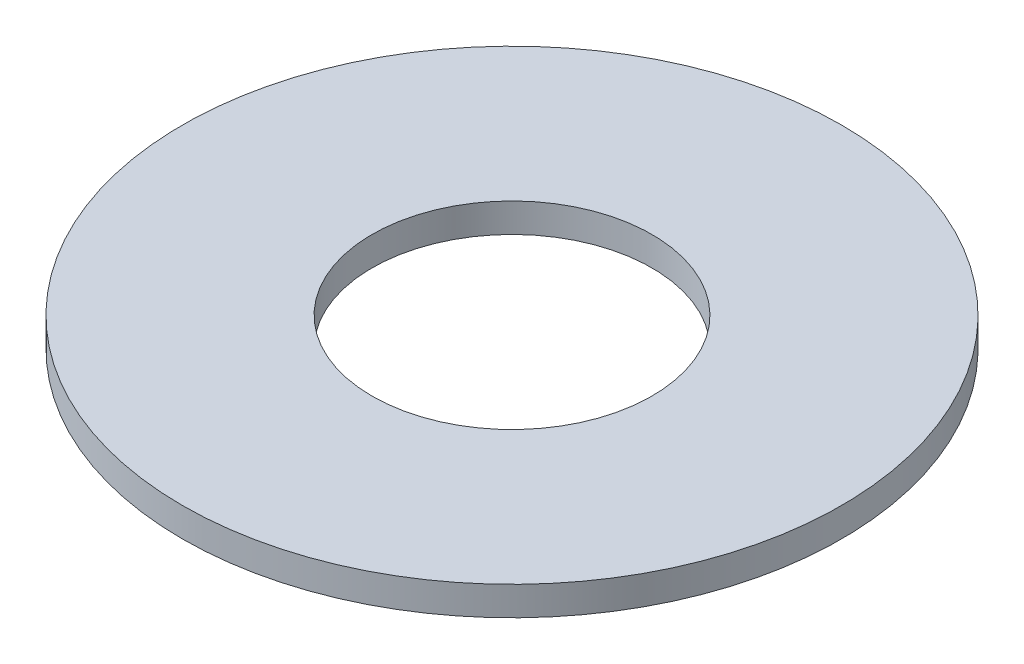
from build123d import *

# Parameters (mm, degrees)
SKETCH1_R           = 15.875
BOSS_EXTRUDE1_DEPTH = 1.397
SKETCH5_R           = 6.7437
CUT_EXTRUDE1_DEPTH  = 2.397


with BuildPart() as part:
    # Sketch1 → Boss-Extrude1 (new body)
    with BuildSketch(Plane(origin=(0, 0, 0), x_dir=(1, 0, 0), z_dir=(0, 1, 0))):
        Circle(SKETCH1_R)
    extrude(amount=BOSS_EXTRUDE1_DEPTH)

    # Sketch5 → Cut-Extrude1 (cut, through all)
    with BuildSketch(Plane(origin=(0, 1.397, 0), x_dir=(-1, 0, 0), z_dir=(0, 1, 0))):
        Circle(SKETCH5_R)
    extrude(amount=-CUT_EXTRUDE1_DEPTH, mode=Mode.SUBTRACT)


solid = part.part
